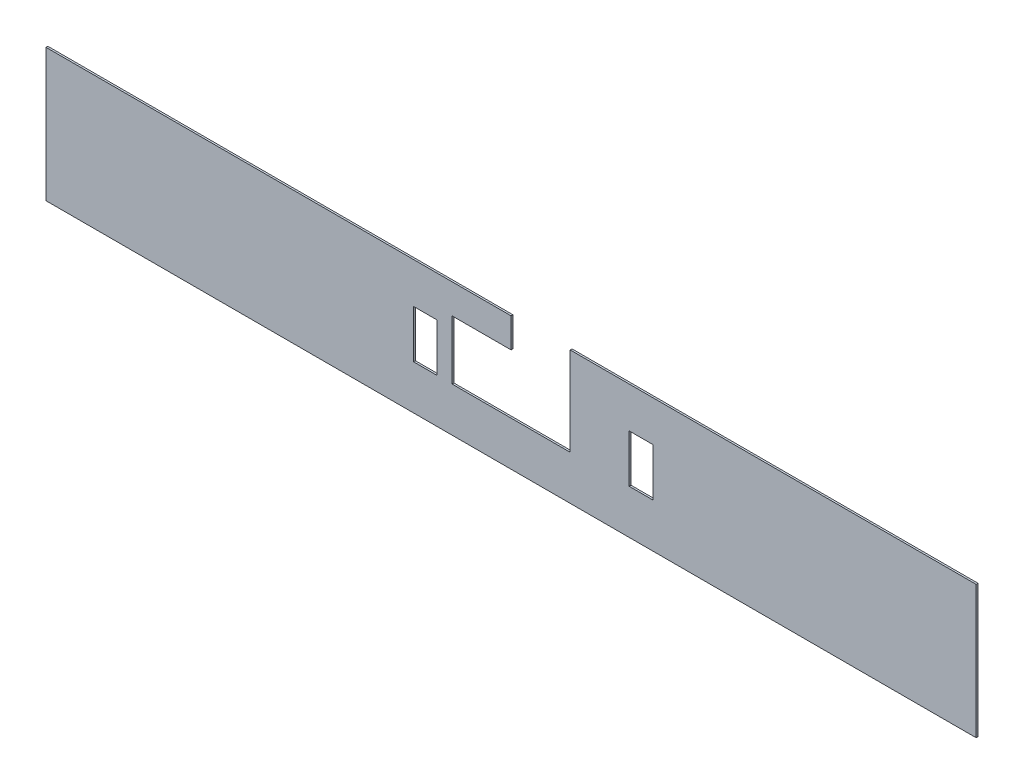
from build123d import *

# Parameters (mm, degrees)
BOSS_EXTRUDE1_DEPTH = 1.6002
SKETCH2_W           = 20.32
SKETCH2_H           = 41.275
CUT_EXTRUDE5_DEPTH  = 2.6002
SKETCH3_W           = 50.8
SKETCH3_H           = 50.8
CUT_EXTRUDE6_DEPTH  = 2.54


with BuildPart() as part:
    # Sketch1 → Boss-Extrude1 (new body)
    with BuildSketch(Plane.XY):
        Polygon((0, 0), (50.8, 0), (50.8, 76.2), (400.05, 76.2), (400.05, -38.1), (-400.05, -38.1), (-400.05, 76.2), (0, 76.2), align=None)
    extrude(amount=BOSS_EXTRUDE1_DEPTH)

    # Sketch2 → Cut-Extrude5 (cut, through all)
    with BuildSketch(Plane.XY):
        with Locations((-73.66, 20.6375)):
            Rectangle(SKETCH2_W, SKETCH2_H)
        with Locations((111.76, 20.6375)):
            Rectangle(SKETCH2_W, SKETCH2_H)
    extrude(amount=CUT_EXTRUDE5_DEPTH, mode=Mode.SUBTRACT)

    # Sketch3 → Cut-Extrude6 (cut)
    with BuildSketch(Plane(origin=(0, 0, 0), x_dir=(-1, 0, 0), z_dir=(0, 0, -1))):
        with Locations((25.4, 25.4)):
            Rectangle(SKETCH3_W, SKETCH3_H)
    extrude(amount=-CUT_EXTRUDE6_DEPTH, mode=Mode.SUBTRACT)


solid = part.part
